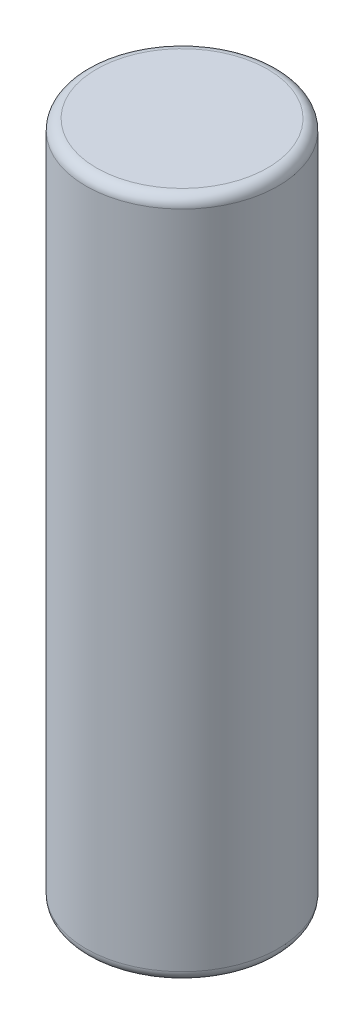
from build123d import *

# Parameters (mm, degrees)
SKETCH1_R           = 9.15
BOSS_EXTRUDE1_DEPTH = 64.9
FILLET1_R           = 1


with BuildPart() as part:
    # Sketch1 → Boss-Extrude1 (new body)
    with BuildSketch(Plane(origin=(0, 0, 0), x_dir=(1, 0, 0), z_dir=(0, 1, 0))):
        Circle(SKETCH1_R)
    extrude(amount=BOSS_EXTRUDE1_DEPTH)

    # Fillet1
    fillet1_edges = [part.edges().sort_by_distance(p)[0] for p in [
        (-9.15, 0, 0),
        (-9.15, 64.9, 0),
    ]]
    fillet(fillet1_edges, radius=FILLET1_R)


solid = part.part
